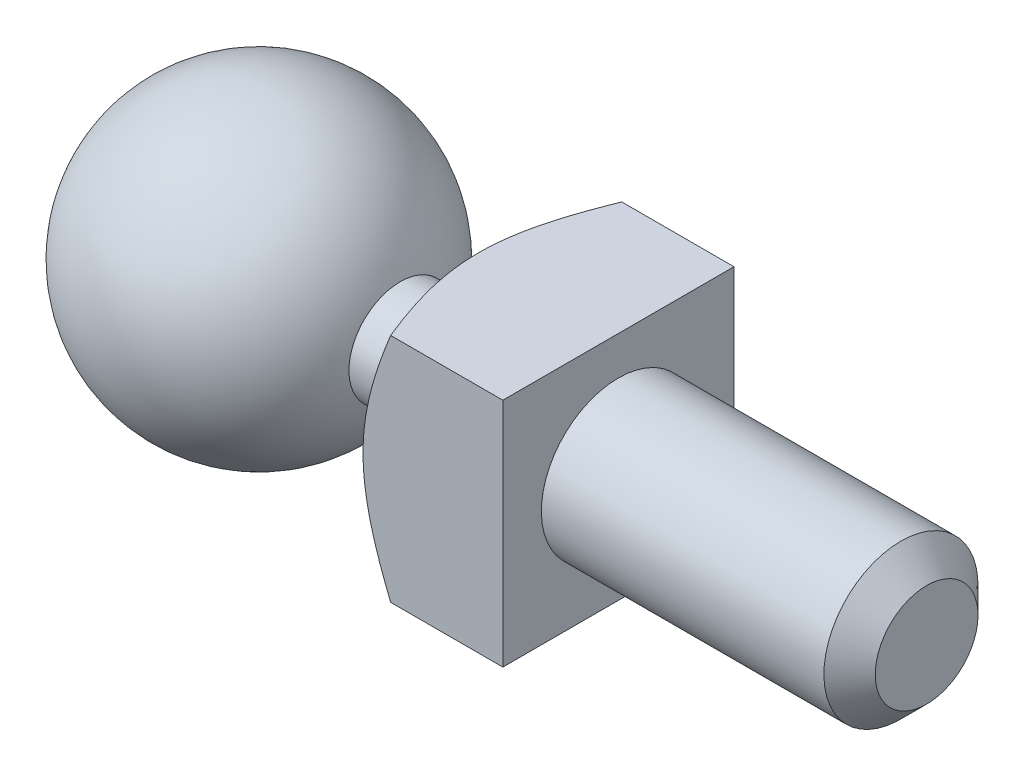
from build123d import *

# Parameters (mm, degrees)
ESQUISSE2_W             = 5.361902648
ESQUISSE2_H             = 1.25
ENL_V_MAT_EXTRU_1_DEPTH = 3
ESQUISSE4_W             = 1.25
ESQUISSE4_H             = 4.5
ENL_V_MAT_EXTRU_2_DEPTH = 2.75
CHANFREIN1_SIZE         = 0.5


with BuildPart() as part:
    # Esquisse1 → Révolution1 (revolve)
    with BuildSketch(Plane.XY):
        with BuildLine():
            Line((2.754069716, 1), (3.556624327, 1))
            Line((3.556624327, 1), (5, 3.5))
            Line((5, 3.5), (7, 3.5))
            Line((7, 3.5), (7, 1.5))
            Line((7, 1.5), (13, 1.5))
            Line((13, 1.5), (13, 0))
            Line((13, 0), (-2.93, 0))
            ThreePointArc((-2.93, 0), (-0.507678901, 2.885682265), (2.754069716, 1))
        make_face()
    revolve(axis=Axis((13, 0, 0), (-1, 0, 0)))

    # Esquisse2 → Enlèv. mat.-Extru.1 (cut)
    with BuildSketch(Plane(origin=(7, 0, 0), x_dir=(0, 0, -1), z_dir=(1, 0, 0))):
        with Locations((0, 2.875)):
            Rectangle(ESQUISSE2_W, ESQUISSE2_H)
        with Locations((0, -2.875)):
            Rectangle(ESQUISSE2_W, ESQUISSE2_H)
    extrude(amount=-ENL_V_MAT_EXTRU_1_DEPTH, mode=Mode.SUBTRACT)

    # Esquisse4 → Enlèv. mat.-Extru.2 (cut)
    with BuildSketch(Plane(origin=(7, 0, 0), x_dir=(0, 0, -1), z_dir=(1, 0, 0))):
        with Locations((2.875, 0)):
            Rectangle(ESQUISSE4_W, ESQUISSE4_H)
        with Locations((-2.875, 0)):
            Rectangle(ESQUISSE4_W, ESQUISSE4_H)
    extrude(amount=-ENL_V_MAT_EXTRU_2_DEPTH, mode=Mode.SUBTRACT)

    # Chanfrein1
    chanfrein1_edges = [part.edges().sort_by_distance(p)[0] for p in [
        (13, -1.5, 0),
    ]]
    chamfer(chanfrein1_edges, length=CHANFREIN1_SIZE)


solid = part.part
